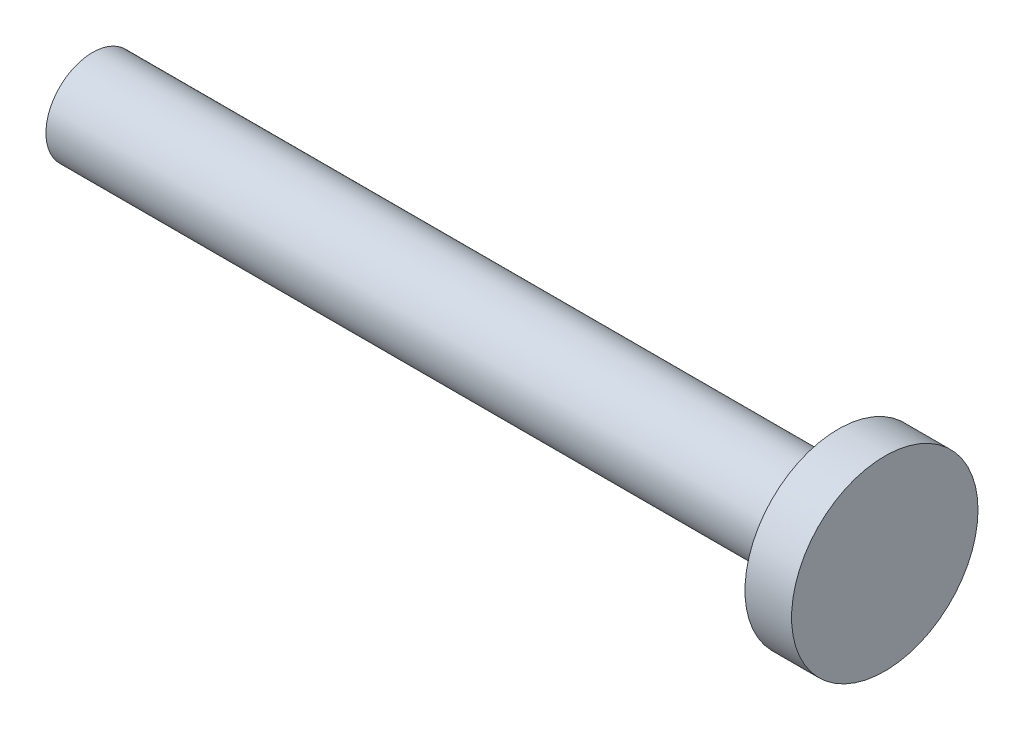
from build123d import *

# Parameters (mm, degrees)
SKETCH1_R           = 6.35
BOSS_EXTRUDE1_DEPTH = 101.6
SKETCH2_R           = 12.7
BOSS_EXTRUDE2_DEPTH = 6.35


with BuildPart() as part:
    # Sketch1 → Boss-Extrude1 (new body)
    with BuildSketch(Plane(origin=(0, 0, 0), x_dir=(0, 0, -1), z_dir=(1, 0, 0))):
        Circle(SKETCH1_R)
    extrude(amount=-BOSS_EXTRUDE1_DEPTH)

    # Sketch2 → Boss-Extrude2 (add)
    with BuildSketch(Plane(origin=(0, 0, 0), x_dir=(0, 0, -1), z_dir=(1, 0, 0))):
        Circle(SKETCH2_R)
    extrude(amount=BOSS_EXTRUDE2_DEPTH)


solid = part.part
